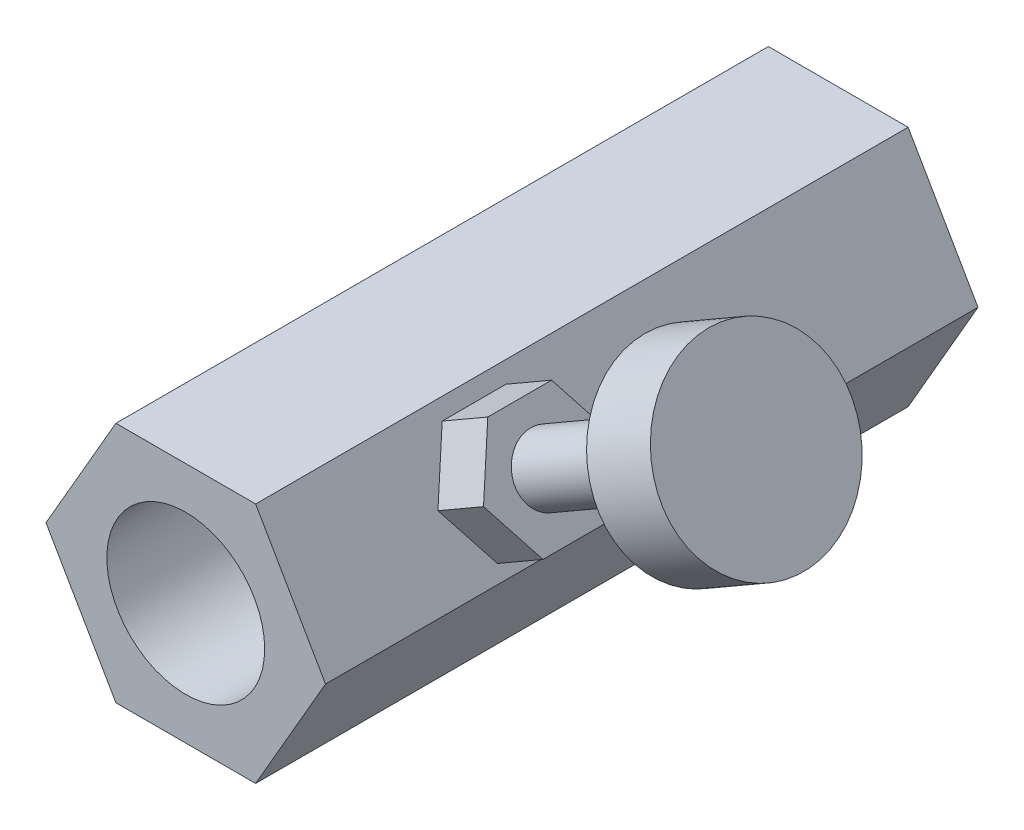
from build123d import *

# Parameters (mm, degrees)
EXTRUDE_1_DEPTH      = 20
EXTRUDE_1_DEPTH_BACK = 42
SKETCH_2_R           = 7.5
CUT_EXTRUDE_1_DEPTH  = 65
EXTRUDE_2_DEPTH      = 5
SKETCH_4_R           = 3
EXTRUDE_3_DEPTH      = 16
SKETCH_5_R           = 9
EXTRUDE_4_DEPTH      = 7
EXTRUDE_5_DEPTH      = 7


with BuildPart() as part:
    # 草图1 → 凸台-拉伸1 (new body, two sides)
    with BuildSketch(Plane.XY) as extrude_1_sk:
        Polygon((-6.639528096, -11.5), (6.639528096, -11.5), (13.279056191, 0), (6.639528096, 11.5), (-6.639528096, 11.5), (-13.279056191, 0), align=None)
    extrude(amount=EXTRUDE_1_DEPTH)
    extrude(extrude_1_sk.sketch, amount=-EXTRUDE_1_DEPTH_BACK)

    # 草图2 → 切除-拉伸1 (cut)
    with BuildSketch(Plane.XY.offset(20)):
        Circle(SKETCH_2_R)
    extrude(amount=-CUT_EXTRUDE_1_DEPTH, mode=Mode.SUBTRACT)

    # 草图3 → 凸台-拉伸2 (add)
    with BuildSketch(Plane(origin=(9.959292144, 5.75, 0), x_dir=(0, 0, -1), z_dir=(0.866025404, 0.5, 0))):
        Polygon((-3.020588915, -5.357215685), (3.041588911, -5.357215685), (6.072677825, -0.107215685), (3.041588911, 5.142784315), (-3.020588915, 5.142784315), (-6.051677828, -0.107215685), align=None)
    extrude(amount=EXTRUDE_2_DEPTH)

    # 草图4 → 凸台-拉伸3 (add)
    with BuildSketch(Plane(origin=(14.289419162, 8.25, 0), x_dir=(0, 0, -1), z_dir=(0.866025404, 0.5, 0))):
        Circle(SKETCH_4_R)
    extrude(amount=EXTRUDE_3_DEPTH)

    # 草图5 → 凸台-拉伸4 (add)
    with BuildSketch(Plane(origin=(28.145825623, 16.25, 0), x_dir=(0, 0, -1), z_dir=(0.866025404, 0.5, 0))):
        Circle(SKETCH_5_R)
    extrude(amount=EXTRUDE_4_DEPTH)

    # 草图6 → 凸台-拉伸5 (add)
    with BuildSketch(Plane(origin=(-9.959292144, -5.75, 0), x_dir=(0, 0, 1), z_dir=(-0.866025404, -0.5, 0))):
        Polygon((-16.732210102, -5.46), (-10.427545163, -5.46), (-7.275212693, 0), (-10.427545163, 5.46), (-16.732210102, 5.46), (-19.884542572, 0), align=None)
    extrude(amount=EXTRUDE_5_DEPTH)


solid = part.part
